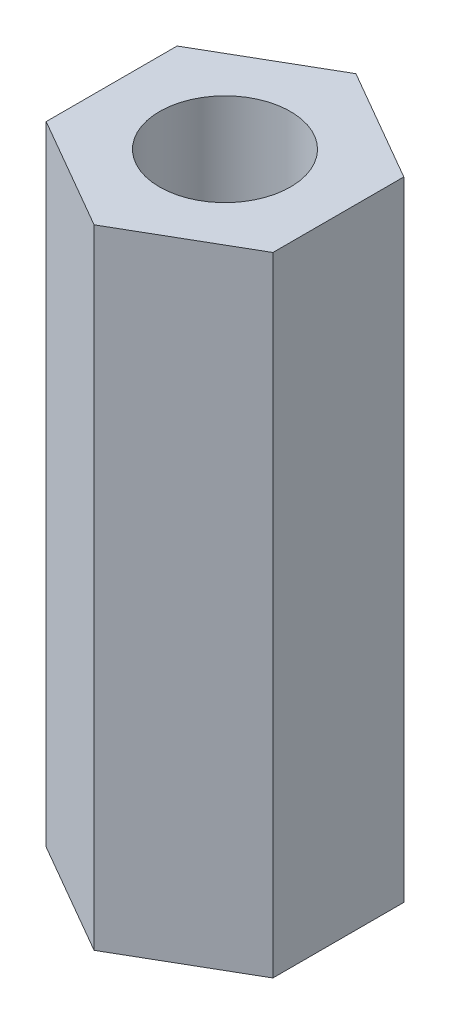
from build123d import *

# Parameters (mm, degrees)
ESQUISSE1_R      = 2.5
EXTRUSION1_DEPTH = 24


with BuildPart() as part:
    # Esquisse1 → Extrusion1 (new body)
    with BuildSketch(Plane(origin=(0, 0, 0), x_dir=(1, 0, 0), z_dir=(0, 1, 0))):
        Polygon((0, 5), (-4.330127019, 2.5), (-4.330127019, -2.5), (0, -5), (4.330127019, -2.5), (4.330127019, 2.5), align=None)
        Circle(ESQUISSE1_R, mode=Mode.SUBTRACT)
    extrude(amount=EXTRUSION1_DEPTH)


solid = part.part
